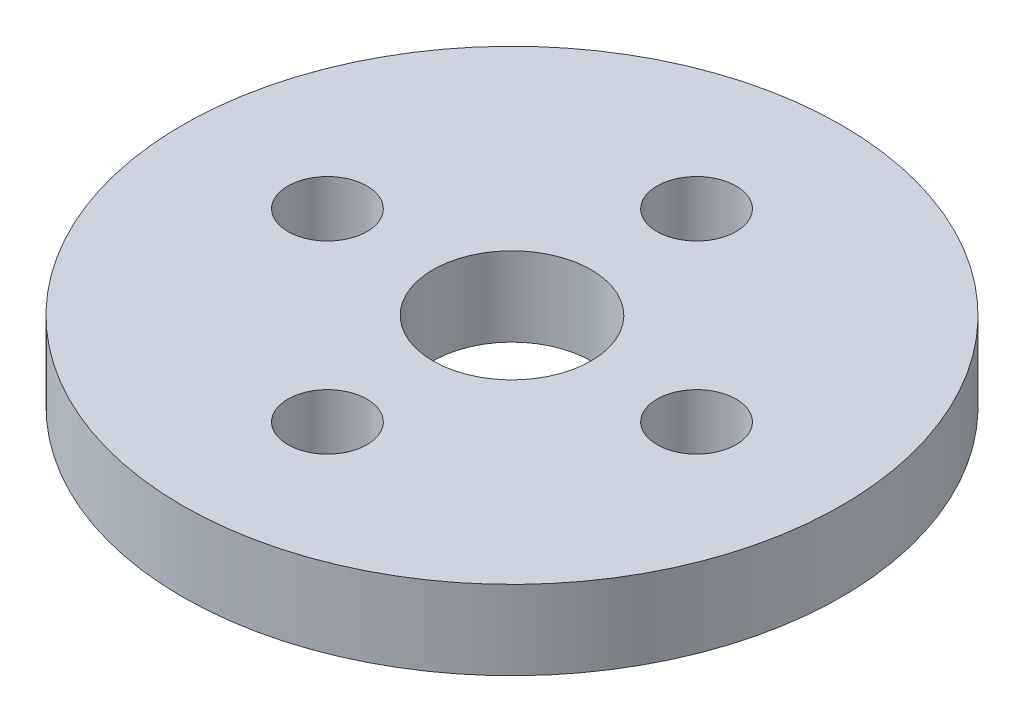
from build123d import *

# Parameters (mm, degrees)
SKETCH1_R           = 12.5
SKETCH1_R_2         = 1.5
SKETCH1_R_3         = 3
BOSS_EXTRUDE1_DEPTH = 3


with BuildPart() as part:
    # Sketch1 → Boss-Extrude1 (new body)
    with BuildSketch(Plane(origin=(0, 0, 0), x_dir=(1, 0, 0), z_dir=(0, 1, 0))):
        Circle(SKETCH1_R)
        with Locations((-7, 0)):
            Circle(SKETCH1_R_2, mode=Mode.SUBTRACT)
        with Locations((0, 7)):
            Circle(SKETCH1_R_2, mode=Mode.SUBTRACT)
        with Locations((7, 0)):
            Circle(SKETCH1_R_2, mode=Mode.SUBTRACT)
        with Locations((0, -7)):
            Circle(SKETCH1_R_2, mode=Mode.SUBTRACT)
        Circle(SKETCH1_R_3, mode=Mode.SUBTRACT)
    extrude(amount=BOSS_EXTRUDE1_DEPTH)


solid = part.part
